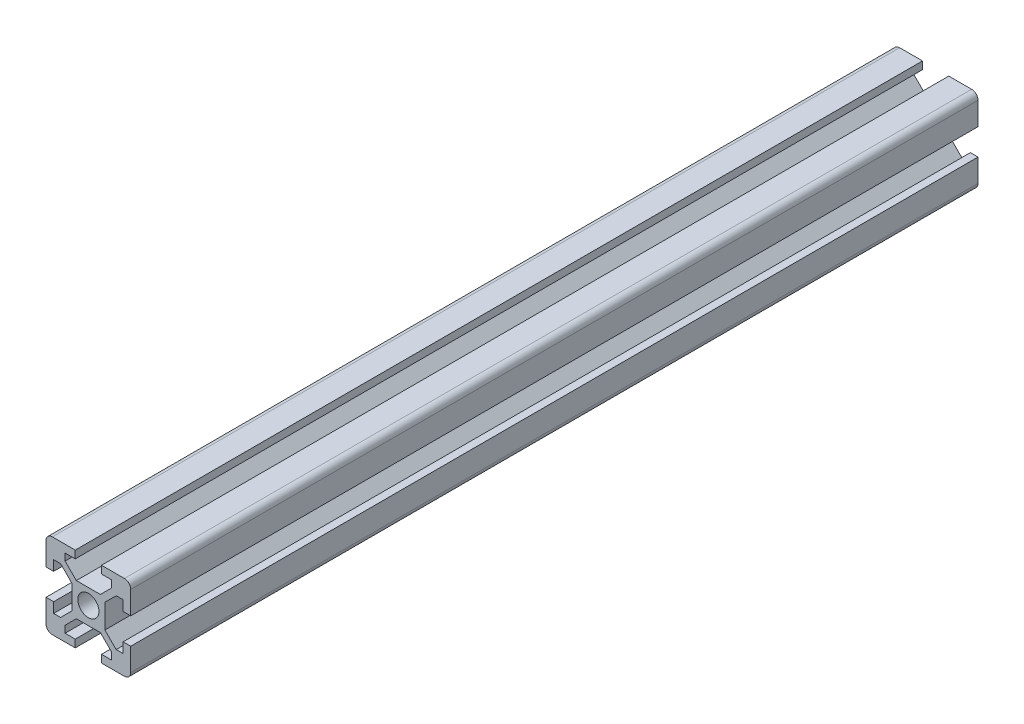
from build123d import *

# Parameters (mm, degrees)
SKETCH1_R           = 2.5
BOSS_EXTRUDE1_DEPTH = 200


with BuildPart() as part:
    # Sketch1 → Boss-Extrude1 (new body)
    with BuildSketch(Plane.XY):
        with BuildLine():
            Line((2.839339828, 3.9), (5.5, 6.560660172))
            Line((5.5, 6.560660172), (5.5, 8.2))
            Line((5.5, 8.2), (3.1, 8.2))
            Line((3.1, 8.2), (3.1, 10))
            Line((3.1, 10), (8.5, 10))
            ThreePointArc((8.5, 10), (9.560660172, 9.560660172), (10, 8.5))
            Line((10, 8.5), (10, 3.1))
            Line((10, 3.1), (8.2, 3.1))
            Line((8.2, 3.1), (8.2, 5.5))
            Line((8.2, 5.5), (6.560660172, 5.5))
            Line((6.560660172, 5.5), (3.9, 2.839339828))
            Line((3.9, 2.839339828), (3.9, -2.839339828))
            Line((3.9, -2.839339828), (6.560660172, -5.5))
            Line((6.560660172, -5.5), (8.2, -5.5))
            Line((8.2, -5.5), (8.2, -3.1))
            Line((8.2, -3.1), (10, -3.1))
            Line((10, -3.1), (10, -8.5))
            ThreePointArc((10, -8.5), (9.560660172, -9.560660172), (8.5, -10))
            Line((8.5, -10), (3.1, -10))
            Line((3.1, -10), (3.1, -8.2))
            Line((3.1, -8.2), (5.5, -8.2))
            Line((5.5, -8.2), (5.5, -6.560660172))
            Line((5.5, -6.560660172), (2.839339828, -3.9))
            Line((2.839339828, -3.9), (-2.839339828, -3.9))
            Line((-2.839339828, -3.9), (-5.5, -6.560660172))
            Line((-5.5, -6.560660172), (-5.5, -8.2))
            Line((-5.5, -8.2), (-3.1, -8.2))
            Line((-3.1, -8.2), (-3.1, -10))
            Line((-3.1, -10), (-8.5, -10))
            ThreePointArc((-8.5, -10), (-9.560660172, -9.560660172), (-10, -8.5))
            Line((-10, -8.5), (-10, -3.1))
            Line((-10, -3.1), (-8.2, -3.1))
            Line((-8.2, -3.1), (-8.2, -5.5))
            Line((-8.2, -5.5), (-6.560660172, -5.5))
            Line((-6.560660172, -5.5), (-3.9, -2.839339828))
            Line((-3.9, -2.839339828), (-3.9, 2.839339828))
            Line((-3.9, 2.839339828), (-6.560660172, 5.5))
            Line((-6.560660172, 5.5), (-8.2, 5.5))
            Line((-8.2, 5.5), (-8.2, 3.1))
            Line((-8.2, 3.1), (-10, 3.1))
            Line((-10, 3.1), (-10, 8.5))
            ThreePointArc((-10, 8.5), (-9.560660172, 9.560660172), (-8.5, 10))
            Line((-8.5, 10), (-3.1, 10))
            Line((-3.1, 10), (-3.1, 8.2))
            Line((-3.1, 8.2), (-5.5, 8.2))
            Line((-5.5, 8.2), (-5.5, 6.560660172))
            Line((-5.5, 6.560660172), (-2.839339828, 3.9))
            Line((-2.839339828, 3.9), (2.839339828, 3.9))
        make_face()
        with Locations((0, 0.235847297)):
            Circle(SKETCH1_R, mode=Mode.SUBTRACT)
    extrude(amount=BOSS_EXTRUDE1_DEPTH)


solid = part.part
